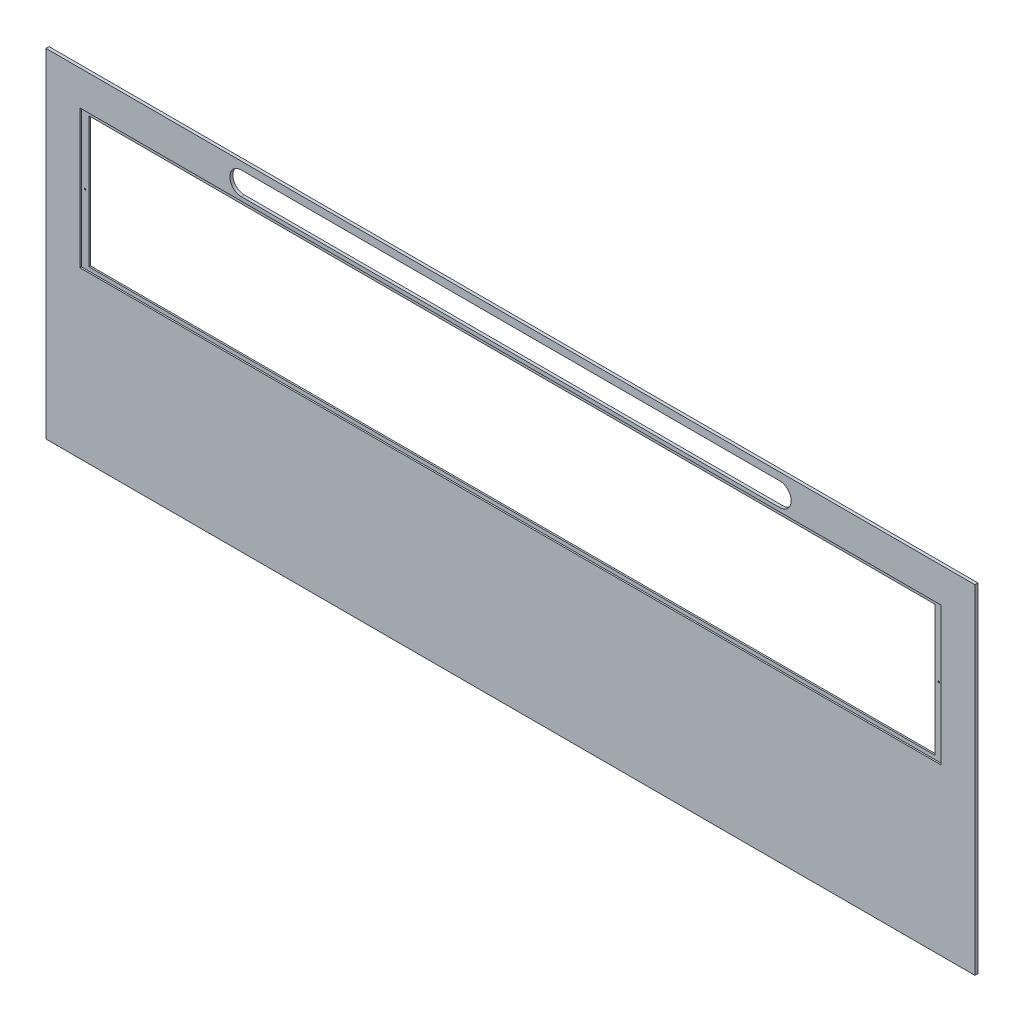
from build123d import *

# Parameters (mm, degrees)
SKETCH1_W           = 1208
SKETCH1_H           = 440
BOSS_EXTRUDE1_DEPTH = 4
CUT_EXTRUDE1_DEPTH  = 10
SKETCH3_W           = 1120
SKETCH3_H           = 180
CUT_EXTRUDE2_DEPTH  = 2
SKETCH4_W           = 1100
SKETCH4_H           = 170
CUT_EXTRUDE3_DEPTH  = 3
SKETCH5_R           = 1
CUT_EXTRUDE4_DEPTH  = 1


with BuildPart() as part:
    # Sketch1 → Boss-Extrude1 (new body)
    with BuildSketch(Plane.XY):
        Rectangle(SKETCH1_W, SKETCH1_H)
    extrude(amount=BOSS_EXTRUDE1_DEPTH)

    # Sketch2 → Cut-Extrude1 (cut)
    with BuildSketch(Plane.XY.offset(4)):
        with BuildLine():
            Line((-350, 210), (350, 210))
            ThreePointArc((350, 210), (365, 195), (350, 180))
            Line((350, 180), (-350, 180))
            ThreePointArc((-350, 180), (-365, 195), (-350, 210))
        make_face()
    extrude(amount=-CUT_EXTRUDE1_DEPTH, mode=Mode.SUBTRACT)

    # Sketch3 → Cut-Extrude2 (cut)
    with BuildSketch(Plane.XY.offset(4)):
        with Locations((0, 85)):
            Rectangle(SKETCH3_W, SKETCH3_H)
    extrude(amount=-CUT_EXTRUDE2_DEPTH, mode=Mode.SUBTRACT)

    # Sketch4 → Cut-Extrude3 (cut, through all)
    with BuildSketch(Plane.XY.offset(2)):
        with Locations((0, 85)):
            Rectangle(SKETCH4_W, SKETCH4_H)
    extrude(amount=-CUT_EXTRUDE3_DEPTH, mode=Mode.SUBTRACT)

    # Sketch5 → Cut-Extrude4 (cut)
    with BuildSketch(Plane.XY.offset(2)):
        with Locations((-555, 85)):
            Circle(SKETCH5_R)
    cut_extrude4 = extrude(amount=-CUT_EXTRUDE4_DEPTH, mode=Mode.SUBTRACT)

    # Mirror1: Cut-Extrude4 across plane
    add(cut_extrude4.mirror(Plane(origin=(0, 0, 0), x_dir=(0, 0, 1), z_dir=(1, 0, 0))), mode=Mode.SUBTRACT)


solid = part.part
